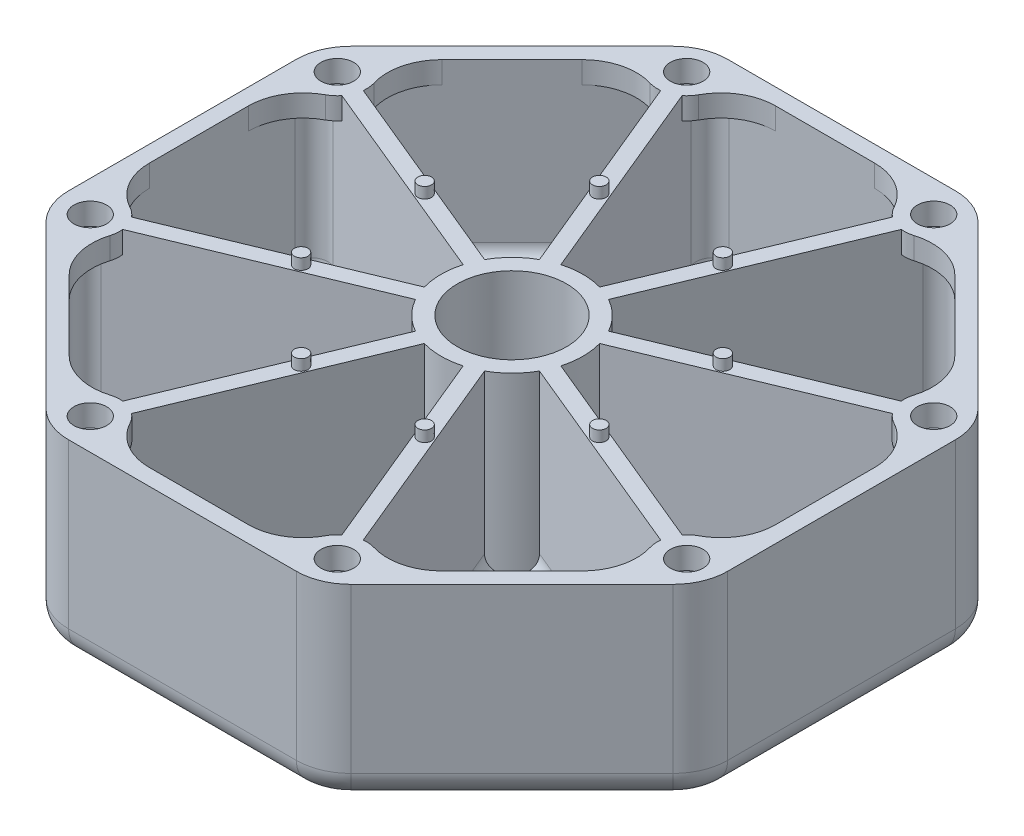
from build123d import *

# Parameters (mm, degrees)
BOSS_EXTRUDE1_DEPTH = 3
SKETCH2_R           = 10
BOSS_EXTRUDE2_DEPTH = 28
SKETCH3_R           = 3
SKETCH3_R_2         = 10
BOSS_EXTRUDE3_DEPTH = 4
SKETCH4_R           = 1.25
BOSS_EXTRUDE4_DEPTH = 2
FILLET1_R           = 5
FILLET3_R           = 3


with BuildPart() as part:
    # Sketch1 → Boss-Extrude1 (new body)
    with BuildSketch(Plane(origin=(0, 0, 0), x_dir=(1, 0, 0), z_dir=(0, 1, 0))):
        with BuildLine():
            Line((27.928932188, -57.426406871), (57.426406871, -27.928932188))
            ThreePointArc((57.426406871, -27.928932188), (59.594134384, -24.6846987), (60.355339059, -20.857864376))
            Line((60.355339059, -20.857864376), (60.355339059, 20.857864376))
            ThreePointArc((60.355339059, 20.857864376), (59.594134384, 24.6846987), (57.426406871, 27.928932188))
            Line((57.426406871, 27.928932188), (27.928932188, 57.426406871))
            ThreePointArc((27.928932188, 57.426406871), (24.6846987, 59.594134384), (20.857864376, 60.355339059))
            Line((20.857864376, 60.355339059), (-20.857864376, 60.355339059))
            ThreePointArc((-20.857864376, 60.355339059), (-24.6846987, 59.594134384), (-27.928932188, 57.426406871))
            Line((-27.928932188, 57.426406871), (-57.426406871, 27.928932188))
            ThreePointArc((-57.426406871, 27.928932188), (-59.594134384, 24.6846987), (-60.355339059, 20.857864376))
            Line((-60.355339059, 20.857864376), (-60.355339059, -20.857864376))
            ThreePointArc((-60.355339059, -20.857864376), (-59.594134384, -24.6846987), (-57.426406871, -27.928932188))
            Line((-57.426406871, -27.928932188), (-27.928932188, -57.426406871))
            ThreePointArc((-27.928932188, -57.426406871), (-24.6846987, -59.594134384), (-20.857864376, -60.355339059))
            Line((-20.857864376, -60.355339059), (20.857864376, -60.355339059))
            ThreePointArc((20.857864376, -60.355339059), (24.6846987, -59.594134384), (27.928932188, -57.426406871))
        make_face()
    extrude(amount=BOSS_EXTRUDE1_DEPTH)

    # Sketch2 → Boss-Extrude2 (add)
    with BuildSketch(Plane(origin=(0, 3, 0), x_dir=(1, 0, 0), z_dir=(0, 1, 0))):
        with BuildLine():
            Line((27.928932188, -57.426406871), (57.426406871, -27.928932188))
            ThreePointArc((57.426406871, -27.928932188), (59.594134384, -24.6846987), (60.355339059, -20.857864376))
            Line((60.355339059, -20.857864376), (60.355339059, 20.857864376))
            ThreePointArc((60.355339059, 20.857864376), (59.594134384, 24.6846987), (57.426406871, 27.928932188))
            Line((57.426406871, 27.928932188), (27.928932188, 57.426406871))
            ThreePointArc((27.928932188, 57.426406871), (24.6846987, 59.594134384), (20.857864376, 60.355339059))
            Line((20.857864376, 60.355339059), (-20.857864376, 60.355339059))
            ThreePointArc((-20.857864376, 60.355339059), (-24.6846987, 59.594134384), (-27.928932188, 57.426406871))
            Line((-27.928932188, 57.426406871), (-57.426406871, 27.928932188))
            ThreePointArc((-57.426406871, 27.928932188), (-59.594134384, 24.6846987), (-60.355339059, 20.857864376))
            Line((-60.355339059, 20.857864376), (-60.355339059, -20.857864376))
            ThreePointArc((-60.355339059, -20.857864376), (-59.594134384, -24.6846987), (-57.426406871, -27.928932188))
            Line((-57.426406871, -27.928932188), (-27.928932188, -57.426406871))
            ThreePointArc((-27.928932188, -57.426406871), (-24.6846987, -59.594134384), (-20.857864376, -60.355339059))
            Line((-20.857864376, -60.355339059), (20.857864376, -60.355339059))
            ThreePointArc((20.857864376, -60.355339059), (24.6846987, -59.594134384), (27.928932188, -57.426406871))
        make_face()
        Circle(SKETCH2_R, mode=Mode.SUBTRACT)
        with BuildLine():
            Line((28.080189861, -53.032508512), (53.032508512, -28.080189861))
            ThreePointArc((53.032508512, -28.080189861), (53.853544009, -25.373598551), (52.059238465, -23.18723092))
            Line((52.059238465, -23.18723092), (11.356189765, -6.327476118))
            ThreePointArc((11.356189765, -6.327476118), (9.192388155, -9.192388155), (6.327476118, -11.356189765))
            Line((6.327476118, -11.356189765), (23.18723092, -52.059238465))
            ThreePointArc((23.18723092, -52.059238465), (25.373598551, -53.853544009), (28.080189861, -53.032508512))
        make_face(mode=Mode.SUBTRACT)
        with BuildLine():
            Line((57.355339059, -17.643953724), (57.355339059, 17.643953724))
            ThreePointArc((57.355339059, 17.643953724), (56.022049758, 20.138362561), (53.207288762, 20.415592322))
            Line((53.207288762, 20.415592322), (12.504240062, 3.55583752))
            ThreePointArc((12.504240062, 3.55583752), (13, 0), (12.504240062, -3.55583752))
            Line((12.504240062, -3.55583752), (53.207288762, -20.415592322))
            ThreePointArc((53.207288762, -20.415592322), (56.022049758, -20.138362561), (57.355339059, -17.643953724))
        make_face(mode=Mode.SUBTRACT)
        with BuildLine():
            Line((53.032508512, 28.080189861), (28.080189861, 53.032508512))
            ThreePointArc((28.080189861, 53.032508512), (25.373598551, 53.853544009), (23.18723092, 52.059238465))
            Line((23.18723092, 52.059238465), (6.327476118, 11.356189765))
            ThreePointArc((6.327476118, 11.356189765), (9.192388155, 9.192388155), (11.356189765, 6.327476118))
            Line((11.356189765, 6.327476118), (52.059238465, 23.18723092))
            ThreePointArc((52.059238465, 23.18723092), (53.853544009, 25.373598551), (53.032508512, 28.080189861))
        make_face(mode=Mode.SUBTRACT)
        with BuildLine():
            Line((17.643953724, 57.355339059), (-17.643953724, 57.355339059))
            ThreePointArc((-17.643953724, 57.355339059), (-20.138362561, 56.022049758), (-20.415592322, 53.207288762))
            Line((-20.415592322, 53.207288762), (-3.55583752, 12.504240062))
            ThreePointArc((-3.55583752, 12.504240062), (0, 13), (3.55583752, 12.504240062))
            Line((3.55583752, 12.504240062), (20.415592322, 53.207288762))
            ThreePointArc((20.415592322, 53.207288762), (20.138362561, 56.022049758), (17.643953724, 57.355339059))
        make_face(mode=Mode.SUBTRACT)
        with BuildLine():
            Line((-28.080189861, 53.032508512), (-53.032508512, 28.080189861))
            ThreePointArc((-53.032508512, 28.080189861), (-53.853544009, 25.373598551), (-52.059238465, 23.18723092))
            Line((-52.059238465, 23.18723092), (-11.356189765, 6.327476118))
            ThreePointArc((-11.356189765, 6.327476118), (-9.192388155, 9.192388155), (-6.327476118, 11.356189765))
            Line((-6.327476118, 11.356189765), (-23.18723092, 52.059238465))
            ThreePointArc((-23.18723092, 52.059238465), (-25.373598551, 53.853544009), (-28.080189861, 53.032508512))
        make_face(mode=Mode.SUBTRACT)
        with BuildLine():
            Line((-57.355339059, 17.643953724), (-57.355339059, -17.643953724))
            ThreePointArc((-57.355339059, -17.643953724), (-56.022049758, -20.138362561), (-53.207288762, -20.415592322))
            Line((-53.207288762, -20.415592322), (-12.504240062, -3.55583752))
            ThreePointArc((-12.504240062, -3.55583752), (-13, 0), (-12.504240062, 3.55583752))
            Line((-12.504240062, 3.55583752), (-53.207288762, 20.415592322))
            ThreePointArc((-53.207288762, 20.415592322), (-56.022049758, 20.138362561), (-57.355339059, 17.643953724))
        make_face(mode=Mode.SUBTRACT)
        with BuildLine():
            Line((-53.032508512, -28.080189861), (-28.080189861, -53.032508512))
            ThreePointArc((-28.080189861, -53.032508512), (-25.373598551, -53.853544009), (-23.18723092, -52.059238465))
            Line((-23.18723092, -52.059238465), (-6.327476118, -11.356189765))
            ThreePointArc((-6.327476118, -11.356189765), (-9.192388155, -9.192388155), (-11.356189765, -6.327476118))
            Line((-11.356189765, -6.327476118), (-52.059238465, -23.18723092))
            ThreePointArc((-52.059238465, -23.18723092), (-53.853544009, -25.373598551), (-53.032508512, -28.080189861))
        make_face(mode=Mode.SUBTRACT)
        with BuildLine():
            Line((-17.643953724, -57.355339059), (17.643953724, -57.355339059))
            ThreePointArc((17.643953724, -57.355339059), (20.138362561, -56.022049758), (20.415592322, -53.207288762))
            Line((20.415592322, -53.207288762), (3.55583752, -12.504240062))
            ThreePointArc((3.55583752, -12.504240062), (0, -13), (-3.55583752, -12.504240062))
            Line((-3.55583752, -12.504240062), (-20.415592322, -53.207288762))
            ThreePointArc((-20.415592322, -53.207288762), (-20.138362561, -56.022049758), (-17.643953724, -57.355339059))
        make_face(mode=Mode.SUBTRACT)
    extrude(amount=BOSS_EXTRUDE2_DEPTH)

    # Sketch3 → Boss-Extrude3 (add)
    with BuildSketch(Plane(origin=(0, 31, 0), x_dir=(1, 0, 0), z_dir=(0, 1, 0))):
        with BuildLine():
            ThreePointArc((-27.928932188, -57.426406871), (-24.6846987, -59.594134384), (-20.857864376, -60.355339059))
            Line((-20.857864376, -60.355339059), (20.857864376, -60.355339059))
            ThreePointArc((20.857864376, -60.355339059), (24.6846987, -59.594134384), (27.928932188, -57.426406871))
            Line((27.928932188, -57.426406871), (57.426406871, -27.928932188))
            ThreePointArc((57.426406871, -27.928932188), (59.594134384, -24.6846987), (60.355339059, -20.857864376))
            Line((60.355339059, -20.857864376), (60.355339059, 20.857864376))
            ThreePointArc((60.355339059, 20.857864376), (59.594134384, 24.6846987), (57.426406871, 27.928932188))
            Line((57.426406871, 27.928932188), (27.928932188, 57.426406871))
            ThreePointArc((27.928932188, 57.426406871), (24.6846987, 59.594134384), (20.857864376, 60.355339059))
            Line((20.857864376, 60.355339059), (-20.857864376, 60.355339059))
            ThreePointArc((-20.857864376, 60.355339059), (-24.6846987, 59.594134384), (-27.928932188, 57.426406871))
            Line((-27.928932188, 57.426406871), (-57.426406871, 27.928932188))
            ThreePointArc((-57.426406871, 27.928932188), (-59.594134384, 24.6846987), (-60.355339059, 20.857864376))
            Line((-60.355339059, 20.857864376), (-60.355339059, -20.857864376))
            ThreePointArc((-60.355339059, -20.857864376), (-59.594134384, -24.6846987), (-57.426406871, -27.928932188))
            Line((-57.426406871, -27.928932188), (-27.928932188, -57.426406871))
        make_face()
        with BuildLine():
            ThreePointArc((-9.069581881, -57.355339059), (-14.205536873, -55.935663431), (-17.883213838, -52.079732325))
            ThreePointArc((-17.883213838, -52.079732325), (-18.488684942, -51.181146423), (-19.261932444, -50.422107439))
            Line((-19.261932444, -50.422107439), (-3.55583752, -12.504240062))
            ThreePointArc((-3.55583752, -12.504240062), (0, -13), (3.55583752, -12.504240062))
            Line((3.55583752, -12.504240062), (19.261932444, -50.422107439))
            ThreePointArc((19.261932444, -50.422107439), (18.488684942, -51.181146423), (17.883213838, -52.079732325))
            ThreePointArc((17.883213838, -52.079732325), (14.205536873, -55.935663431), (9.069581881, -57.355339059))
            Line((9.069581881, -57.355339059), (-9.069581881, -57.355339059))
        make_face(mode=Mode.SUBTRACT)
        with Locations((22.624947831, -54.621455902)):
            Circle(SKETCH3_R, mode=Mode.SUBTRACT)
        with BuildLine():
            ThreePointArc((34.143186335, -46.969512037), (29.507655469, -49.597318375), (24.180590115, -49.471273664))
            ThreePointArc((24.180590115, -49.471273664), (23.117061207, -49.264010202), (22.033571042, -49.274057142))
            Line((22.033571042, -49.274057142), (6.327476118, -11.356189765))
            ThreePointArc((6.327476118, -11.356189765), (9.192388155, -9.192388155), (11.356189765, -6.327476118))
            Line((11.356189765, -6.327476118), (49.274057142, -22.033571042))
            ThreePointArc((49.274057142, -22.033571042), (49.264010202, -23.117061207), (49.471273664, -24.180590115))
            ThreePointArc((49.471273664, -24.180590115), (49.597318375, -29.507655469), (46.969512037, -34.143186335))
            Line((46.969512037, -34.143186335), (34.143186335, -46.969512037))
        make_face(mode=Mode.SUBTRACT)
        with Locations((54.621455902, -22.624947831)):
            Circle(SKETCH3_R, mode=Mode.SUBTRACT)
        with BuildLine():
            ThreePointArc((57.355339059, -9.069581881), (55.935663431, -14.205536873), (52.079732325, -17.883213838))
            ThreePointArc((52.079732325, -17.883213838), (51.181146423, -18.488684942), (50.422107439, -19.261932444))
            Line((50.422107439, -19.261932444), (12.504240062, -3.55583752))
            ThreePointArc((12.504240062, -3.55583752), (13, 0), (12.504240062, 3.55583752))
            Line((12.504240062, 3.55583752), (50.422107439, 19.261932444))
            ThreePointArc((50.422107439, 19.261932444), (51.181146423, 18.488684942), (52.079732325, 17.883213838))
            ThreePointArc((52.079732325, 17.883213838), (55.935663431, 14.205536873), (57.355339059, 9.069581881))
            Line((57.355339059, 9.069581881), (57.355339059, -9.069581881))
        make_face(mode=Mode.SUBTRACT)
        with Locations((54.621455902, 22.624947831)):
            Circle(SKETCH3_R, mode=Mode.SUBTRACT)
        with BuildLine():
            ThreePointArc((46.969512037, 34.143186335), (49.597318375, 29.507655469), (49.471273664, 24.180590115))
            ThreePointArc((49.471273664, 24.180590115), (49.264010202, 23.117061207), (49.274057142, 22.033571042))
            Line((49.274057142, 22.033571042), (11.356189765, 6.327476118))
            ThreePointArc((11.356189765, 6.327476118), (9.192388155, 9.192388155), (6.327476118, 11.356189765))
            Line((6.327476118, 11.356189765), (22.033571042, 49.274057142))
            ThreePointArc((22.033571042, 49.274057142), (23.117061207, 49.264010202), (24.180590115, 49.471273664))
            ThreePointArc((24.180590115, 49.471273664), (29.507655469, 49.597318375), (34.143186335, 46.969512037))
            Line((34.143186335, 46.969512037), (46.969512037, 34.143186335))
        make_face(mode=Mode.SUBTRACT)
        with Locations((22.624947831, 54.621455902)):
            Circle(SKETCH3_R, mode=Mode.SUBTRACT)
        with BuildLine():
            ThreePointArc((9.069581881, 57.355339059), (14.205536873, 55.935663431), (17.883213838, 52.079732325))
            ThreePointArc((17.883213838, 52.079732325), (18.488684942, 51.181146423), (19.261932444, 50.422107439))
            Line((19.261932444, 50.422107439), (3.55583752, 12.504240062))
            ThreePointArc((3.55583752, 12.504240062), (0, 13), (-3.55583752, 12.504240062))
            Line((-3.55583752, 12.504240062), (-19.261932444, 50.422107439))
            ThreePointArc((-19.261932444, 50.422107439), (-18.488684942, 51.181146423), (-17.883213838, 52.079732325))
            ThreePointArc((-17.883213838, 52.079732325), (-14.205536873, 55.935663431), (-9.069581881, 57.355339059))
            Line((-9.069581881, 57.355339059), (9.069581881, 57.355339059))
        make_face(mode=Mode.SUBTRACT)
        with Locations((-22.624947831, 54.621455902)):
            Circle(SKETCH3_R, mode=Mode.SUBTRACT)
        with BuildLine():
            ThreePointArc((-34.143186335, 46.969512037), (-29.507655469, 49.597318375), (-24.180590115, 49.471273664))
            ThreePointArc((-24.180590115, 49.471273664), (-23.117061207, 49.264010202), (-22.033571042, 49.274057142))
            Line((-22.033571042, 49.274057142), (-6.327476118, 11.356189765))
            ThreePointArc((-6.327476118, 11.356189765), (-9.192388155, 9.192388155), (-11.356189765, 6.327476118))
            Line((-11.356189765, 6.327476118), (-49.274057142, 22.033571042))
            ThreePointArc((-49.274057142, 22.033571042), (-49.264010202, 23.117061207), (-49.471273664, 24.180590115))
            ThreePointArc((-49.471273664, 24.180590115), (-49.597318375, 29.507655469), (-46.969512037, 34.143186335))
            Line((-46.969512037, 34.143186335), (-34.143186335, 46.969512037))
        make_face(mode=Mode.SUBTRACT)
        with Locations((-54.621455902, 22.624947831)):
            Circle(SKETCH3_R, mode=Mode.SUBTRACT)
        with BuildLine():
            ThreePointArc((-57.355339059, 9.069581881), (-55.935663431, 14.205536873), (-52.079732325, 17.883213838))
            ThreePointArc((-52.079732325, 17.883213838), (-51.181146423, 18.488684942), (-50.422107439, 19.261932444))
            Line((-50.422107439, 19.261932444), (-12.504240062, 3.55583752))
            ThreePointArc((-12.504240062, 3.55583752), (-13, 0), (-12.504240062, -3.55583752))
            Line((-12.504240062, -3.55583752), (-50.422107439, -19.261932444))
            ThreePointArc((-50.422107439, -19.261932444), (-51.181146423, -18.488684942), (-52.079732325, -17.883213838))
            ThreePointArc((-52.079732325, -17.883213838), (-55.935663431, -14.205536873), (-57.355339059, -9.069581881))
            Line((-57.355339059, -9.069581881), (-57.355339059, 9.069581881))
        make_face(mode=Mode.SUBTRACT)
        with Locations((-54.621455902, -22.624947831)):
            Circle(SKETCH3_R, mode=Mode.SUBTRACT)
        with BuildLine():
            ThreePointArc((-46.969512037, -34.143186335), (-49.597318375, -29.507655469), (-49.471273664, -24.180590115))
            ThreePointArc((-49.471273664, -24.180590115), (-49.264010202, -23.117061207), (-49.274057142, -22.033571042))
            Line((-49.274057142, -22.033571042), (-11.356189765, -6.327476118))
            ThreePointArc((-11.356189765, -6.327476118), (-9.192388155, -9.192388155), (-6.327476118, -11.356189765))
            Line((-6.327476118, -11.356189765), (-22.033571042, -49.274057142))
            ThreePointArc((-22.033571042, -49.274057142), (-23.117061207, -49.264010202), (-24.180590115, -49.471273664))
            ThreePointArc((-24.180590115, -49.471273664), (-29.507655469, -49.597318375), (-34.143186335, -46.969512037))
            Line((-34.143186335, -46.969512037), (-46.969512037, -34.143186335))
        make_face(mode=Mode.SUBTRACT)
        with Locations((-22.624947831, -54.621455902)):
            Circle(SKETCH3_R, mode=Mode.SUBTRACT)
        Circle(SKETCH3_R_2, mode=Mode.SUBTRACT)
    extrude(amount=BOSS_EXTRUDE3_DEPTH)

    # Sketch4 → Boss-Extrude4 (add)
    with BuildSketch(Plane(origin=(0, 35, 0), x_dir=(1, 0, 0), z_dir=(0, 1, 0))):
        with Locations((11.312473916, -27.310727951)):
            Circle(SKETCH4_R)
        with Locations((-11.312473916, -27.310727951)):
            Circle(SKETCH4_R)
        with Locations((-27.310727951, -11.312473916)):
            Circle(SKETCH4_R)
        with Locations((-27.310727951, 11.312473916)):
            Circle(SKETCH4_R)
        with Locations((-11.312473916, 27.310727951)):
            Circle(SKETCH4_R)
        with Locations((11.312473916, 27.310727951)):
            Circle(SKETCH4_R)
        with Locations((27.310727951, 11.312473916)):
            Circle(SKETCH4_R)
        with Locations((27.310727951, -11.312473916)):
            Circle(SKETCH4_R)
    extrude(amount=BOSS_EXTRUDE4_DEPTH)

    # Fillet1
    fillet1_edges = [part.edges().sort_by_distance(p)[0] for p in [
        (0, 0, -60.355339059),
        (24.6846987, 0, -59.594134384),
        (42.67766953, 0, -42.67766953),
        (59.594134384, 0, -24.6846987),
        (60.355339059, 0, 0),
        (59.594134384, 0, 24.6846987),
        (42.67766953, 0, 42.67766953),
        (24.6846987, 0, 59.594134384),
        (0, 0, 60.355339059),
        (-24.6846987, 0, 59.594134384),
        (-42.67766953, 0, 42.67766953),
        (-59.594134384, 0, 24.6846987),
        (-60.355339059, 0, 0),
        (-59.594134384, 0, -24.6846987),
        (-42.67766953, 0, -42.67766953),
        (-24.6846987, 0, -59.594134384),
    ]]
    fillet(fillet1_edges, radius=FILLET1_R)

    # Fillet3
    fillet3_edges = [part.edges().sort_by_distance(p)[0] for p in [
        (32.855764412, 3, 11.985714921),
        (56.022049758, 3, 20.138362561),
        (57.355339059, 3, 0),
        (56.022049758, 3, -20.138362561),
        (32.855764412, 3, -11.985714921),
        (11.985714921, 3, -32.855764412),
        (20.138362561, 3, -56.022049758),
        (0, 3, -57.355339059),
        (-20.138362561, 3, -56.022049758),
        (-11.985714921, 3, -32.855764412),
        (-32.855764412, 3, -11.985714921),
        (-56.022049758, 3, -20.138362561),
        (-57.355339059, 3, 0),
        (-56.022049758, 3, 20.138362561),
        (-32.855764412, 3, 11.985714921),
        (-11.985714921, 3, 32.855764412),
        (-20.138362561, 3, 56.022049758),
        (0, 3, 57.355339059),
        (20.138362561, 3, 56.022049758),
        (11.985714921, 3, 32.855764412),
        (-31.707714115, 3, 14.757353519),
        (-53.853544009, 3, 25.373598551),
        (-40.556349186, 3, 40.556349186),
        (-25.373598551, 3, 53.853544009),
        (-14.757353519, 3, 31.707714115),
        (-14.757353519, 3, -31.707714115),
        (-25.373598551, 3, -53.853544009),
        (-40.556349186, 3, -40.556349186),
        (-53.853544009, 3, -25.373598551),
        (-31.707714115, 3, -14.757353519),
        (31.707714115, 3, -14.757353519),
        (53.853544009, 3, -25.373598551),
        (40.556349186, 3, -40.556349186),
        (25.373598551, 3, -53.853544009),
        (14.757353519, 3, -31.707714115),
        (14.757353519, 3, 31.707714115),
        (25.373598551, 3, 53.853544009),
        (40.556349186, 3, 40.556349186),
        (53.853544009, 3, 25.373598551),
        (31.707714115, 3, 14.757353519),
    ]]
    fillet(fillet3_edges, radius=FILLET3_R)


solid = part.part
